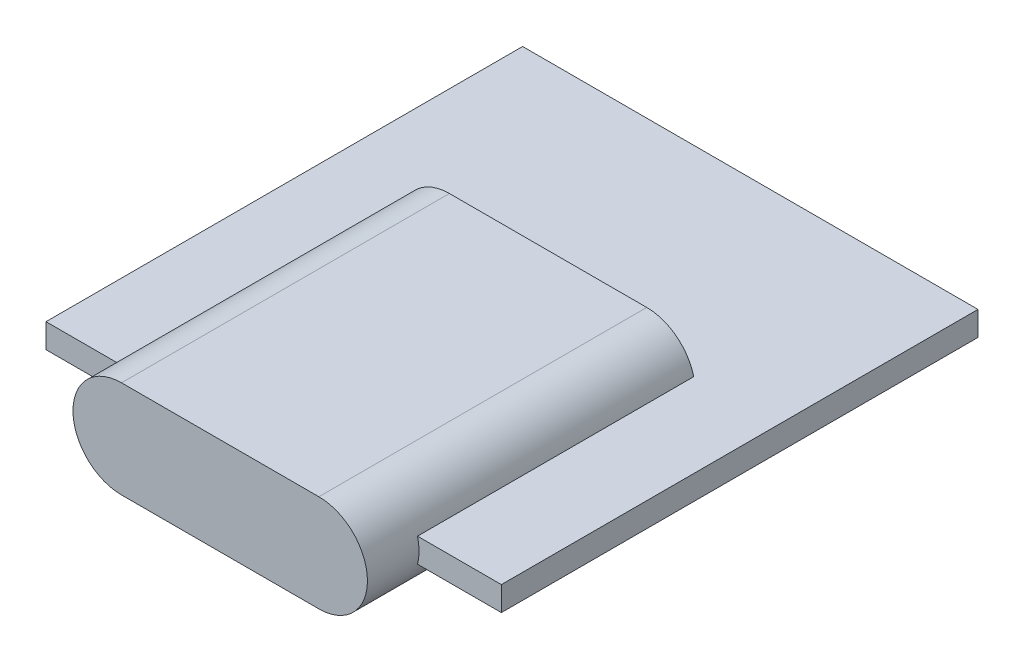
from build123d import *

# Parameters (mm, degrees)
SKETCH1_W           = 15
SKETCH1_H           = 15.7
BOSS_EXTRUDE1_DEPTH = 0.8
BOSS_EXTRUDE2_DEPTH = 10.8


with BuildPart() as part:
    # Sketch1 → Boss-Extrude1 (new body)
    with BuildSketch(Plane(origin=(0, 0, 0), x_dir=(1, 0, 0), z_dir=(0, 1, 0))):
        with Locations((0.367290749, -0.172907489)):
            Rectangle(SKETCH1_W, SKETCH1_H)
    extrude(amount=BOSS_EXTRUDE1_DEPTH)

    # Sketch2 → Boss-Extrude2 (add)
    with BuildSketch(Plane.XY.offset(9.722907489)):
        with BuildLine():
            Line((-2.944438856, 2), (3.555561144, 2))
            ThreePointArc((3.555561144, 2), (5.155561144, 0.4), (3.555561144, -1.2))
            Line((3.555561144, -1.2), (-2.944438856, -1.2))
            ThreePointArc((-2.944438856, -1.2), (-4.544438856, 0.4), (-2.944438856, 2))
        make_face()
    extrude(amount=-BOSS_EXTRUDE2_DEPTH)


solid = part.part
